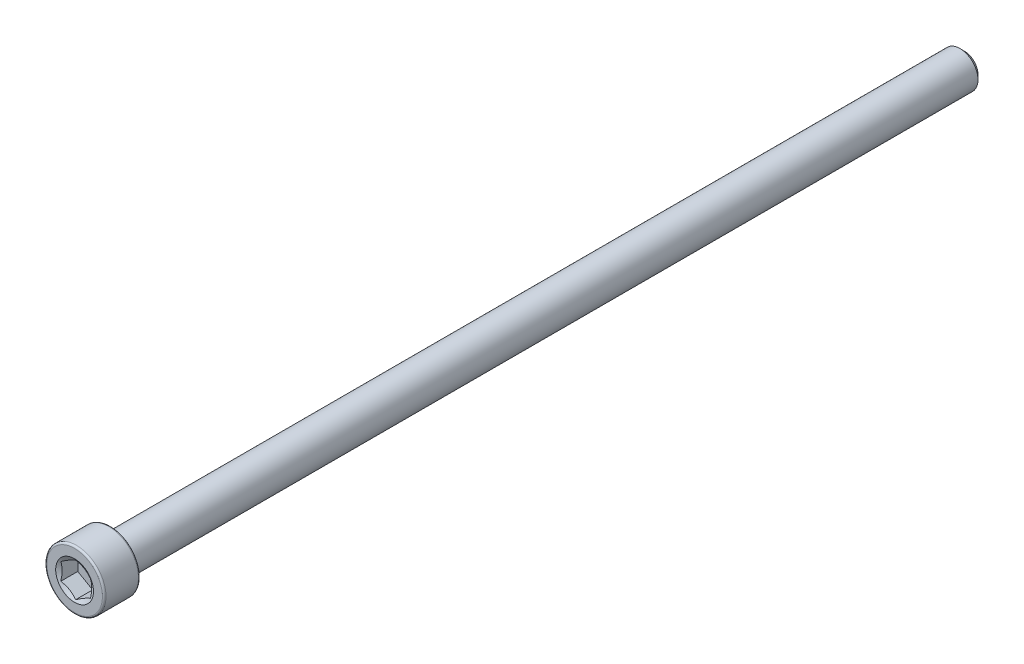
from build123d import *

# Parameters (mm, degrees)
CUT_EXTRUDE1_START = 59.563
CUT_EXTRUDE1_DEPTH = 2.413


with BuildPart() as part:
    # Sketch2 → Revolve1 (revolve)
    with BuildSketch(Plane(origin=(0, 0, 0), x_dir=(0, 0, -1), z_dir=(1, 0, 0)), mode=Mode.PRIVATE) as revolve1_sk:
        with BuildLine():
            Line((59.563, 0), (59.563, 1.8176875))
            Line((59.563, 1.8176875), (58.9676875, 2.413))
            Line((58.9676875, 2.413), (-54.737, 2.413))
            Line((-54.737, 2.413), (-54.737, 3.72745))
            ThreePointArc((-54.737, 3.72745), (-54.807675134, 3.898074866), (-54.9783, 3.96875))
            Line((-54.9783, 3.96875), (-59.3217, 3.96875))
            ThreePointArc((-59.3217, 3.96875), (-59.492324866, 3.898074866), (-59.563, 3.72745))
            Line((-59.563, 3.72745), (-59.563, 0))
            Line((-59.563, 0), (59.563, 0))
        make_face()
    revolve(revolve1_sk.sketch.rotate(Axis((0, 0, -59.563), (0, 0, 1)), 90), axis=Axis((0, 0, -59.563), (0, 0, 1)))

    # Sketch3 → Cut-Extrude1 (cut)
    with BuildSketch(Plane.XY.offset(CUT_EXTRUDE1_START)):
        Polygon((-1.984375, 1.14567944), (-1.984375, -1.14567944), (0, -2.291358881), (1.984375, -1.14567944), (1.984375, 1.14567944), (0, 2.291358881), align=None)
    extrude(amount=-CUT_EXTRUDE1_DEPTH, mode=Mode.SUBTRACT)

    # Cut-Extrude2 cone 1 section (through the dimple's axis) → Cut-Extrude2 (revolve, cut)
    with BuildSketch(Plane(origin=(0, 0, 59.563), x_dir=(0, -1, 0), z_dir=(1, 0, 0))):
        Polygon((0, 0), (2.530707401, 0), (0, 1.461104599), align=None)
    revolve(axis=Axis((0, 0, 59.563), (0, 0, -1)), mode=Mode.SUBTRACT)


solid = part.part
